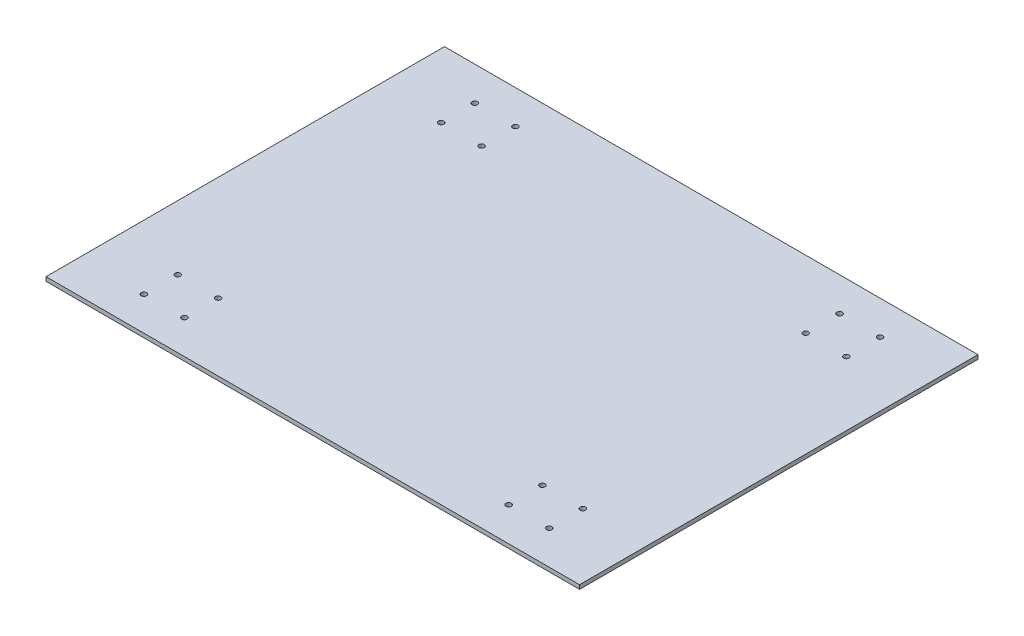
from build123d import *

# Parameters (mm, degrees)
SKETCH1_W           = 395
SKETCH1_H           = 295
BOSS_EXTRUDE1_DEPTH = 3
SKETCH2_R           = 2
CUT_EXTRUDE1_DEPTH  = 4


with BuildPart() as part:
    # Sketch1 → Boss-Extrude1 (new body)
    with BuildSketch(Plane(origin=(0, 0, 0), x_dir=(1, 0, 0), z_dir=(0, 1, 0))):
        Rectangle(SKETCH1_W, SKETCH1_H)
    extrude(amount=BOSS_EXTRUDE1_DEPTH)

    # Sketch2 → Cut-Extrude1 (cut, through all)
    with BuildSketch(Plane(origin=(0, 3, 0), x_dir=(1, 0, 0), z_dir=(0, 1, 0))):
        with Locations((150, -122.5)):
            Circle(SKETCH2_R)
        with Locations((120, -122.5)):
            Circle(SKETCH2_R)
        with Locations((150, -97.5)):
            Circle(SKETCH2_R)
        with Locations((120, -97.5)):
            Circle(SKETCH2_R)
        with Locations((150, 97.5)):
            Circle(SKETCH2_R)
        with Locations((120, 97.5)):
            Circle(SKETCH2_R)
        with Locations((150, 122.5)):
            Circle(SKETCH2_R)
        with Locations((120, 122.5)):
            Circle(SKETCH2_R)
        with Locations((-120, -122.5)):
            Circle(SKETCH2_R)
        with Locations((-150, -122.5)):
            Circle(SKETCH2_R)
        with Locations((-120, -97.5)):
            Circle(SKETCH2_R)
        with Locations((-150, -97.5)):
            Circle(SKETCH2_R)
        with Locations((-120, 97.5)):
            Circle(SKETCH2_R)
        with Locations((-150, 97.5)):
            Circle(SKETCH2_R)
        with Locations((-120, 122.5)):
            Circle(SKETCH2_R)
        with Locations((-150, 122.5)):
            Circle(SKETCH2_R)
    extrude(amount=-CUT_EXTRUDE1_DEPTH, mode=Mode.SUBTRACT)


solid = part.part
